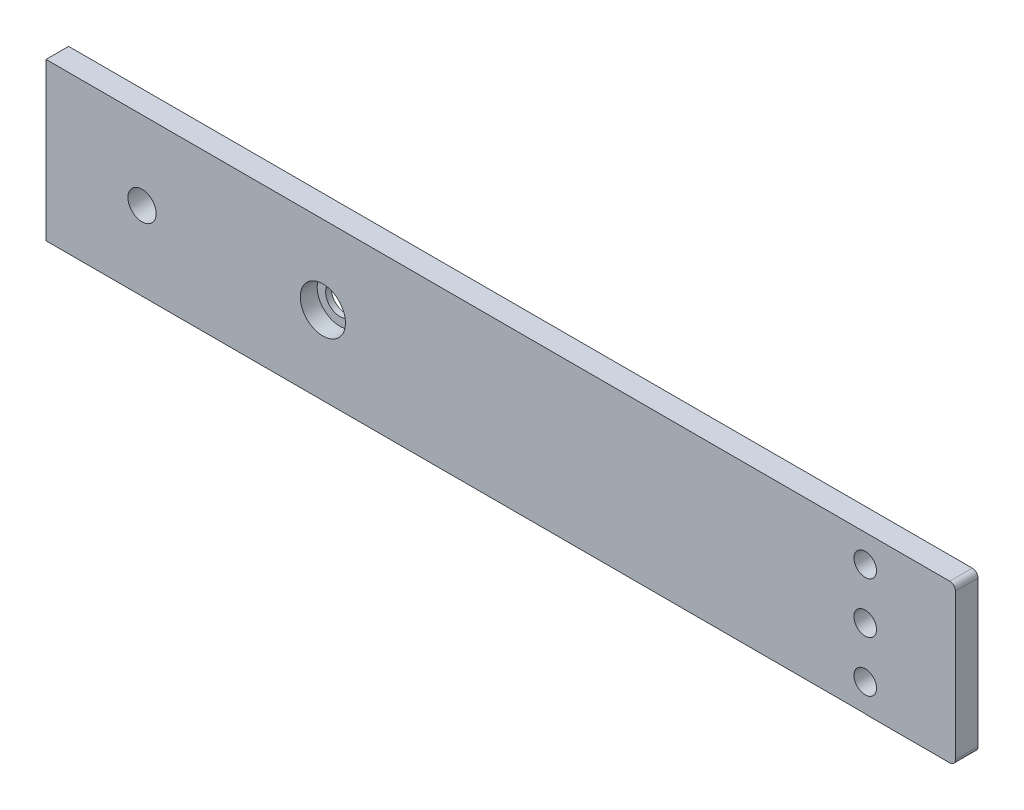
from build123d import *

# Parameters (mm, degrees)
SKETCH_1_R          = 2.5
SKETCH_1_R_2        = 2
EXTRUDE_1_DEPTH     = 4
SKETCH_2_R          = 2
CUT_EXTRUDE_1_DEPTH = 10
SKETCH_4_R          = 4
CUT_EXTRUDE_2_DEPTH = 3


with BuildPart() as part:
    # 草图1 → 凸台-拉伸1 (new body)
    with BuildSketch(Plane.XY):
        with BuildLine():
            Line((-75.538677918, 13.9), (52.461322082, 13.9))
            Line((52.461322082, 13.9), (65.422072845, 13.9))
            Line((65.422072845, 13.9), (67.422072845, 13.9))
            ThreePointArc((67.422072845, 13.9), (68.129179626, 13.607106781), (68.422072845, 12.9))
            Line((68.422072845, 12.9), (68.422072845, 10.9))
            Line((68.422072845, 10.9), (68.422072845, -12.95))
            ThreePointArc((68.422072845, -12.95), (68.129179626, -13.657106781), (67.422072845, -13.95))
            Line((67.422072845, -13.95), (52.461322082, -13.95))
            Line((52.461322082, -13.95), (52.461322082, -13.9))
            Line((52.461322082, -13.9), (-75.538677918, -13.9))
            Line((-75.538677918, -13.9), (-92.538677918, -13.9))
            Line((-92.538677918, -13.9), (-92.538677918, 13.9))
            Line((-92.538677918, 13.9), (-75.538677918, 13.9))
        make_face()
        with Locations((-75.538677918, 0)):
            Circle(SKETCH_1_R, mode=Mode.SUBTRACT)
        with Locations((52.461322082, 0)):
            Circle(SKETCH_1_R_2, mode=Mode.SUBTRACT)
        with Locations((-43.538677918, 0)):
            Circle(SKETCH_1_R, mode=Mode.SUBTRACT)
    extrude(amount=EXTRUDE_1_DEPTH)

    # 草图2 → 切除-拉伸1 (cut)
    with BuildSketch(Plane(origin=(0, 0, 0), x_dir=(-1, 0, 0), z_dir=(0, 0, -1))):
        with Locations((-52.461322082, -9)):
            Circle(SKETCH_2_R)
        with Locations((-52.461322082, 9)):
            Circle(SKETCH_2_R)
    extrude(amount=-CUT_EXTRUDE_1_DEPTH, mode=Mode.SUBTRACT)

    # 草图4 → 切除-拉伸2 (cut)
    with BuildSketch(Plane.XY.offset(4)):
        with Locations((-43.538677918, 0)):
            Circle(SKETCH_4_R)
    extrude(amount=-CUT_EXTRUDE_2_DEPTH, mode=Mode.SUBTRACT)


solid = part.part
